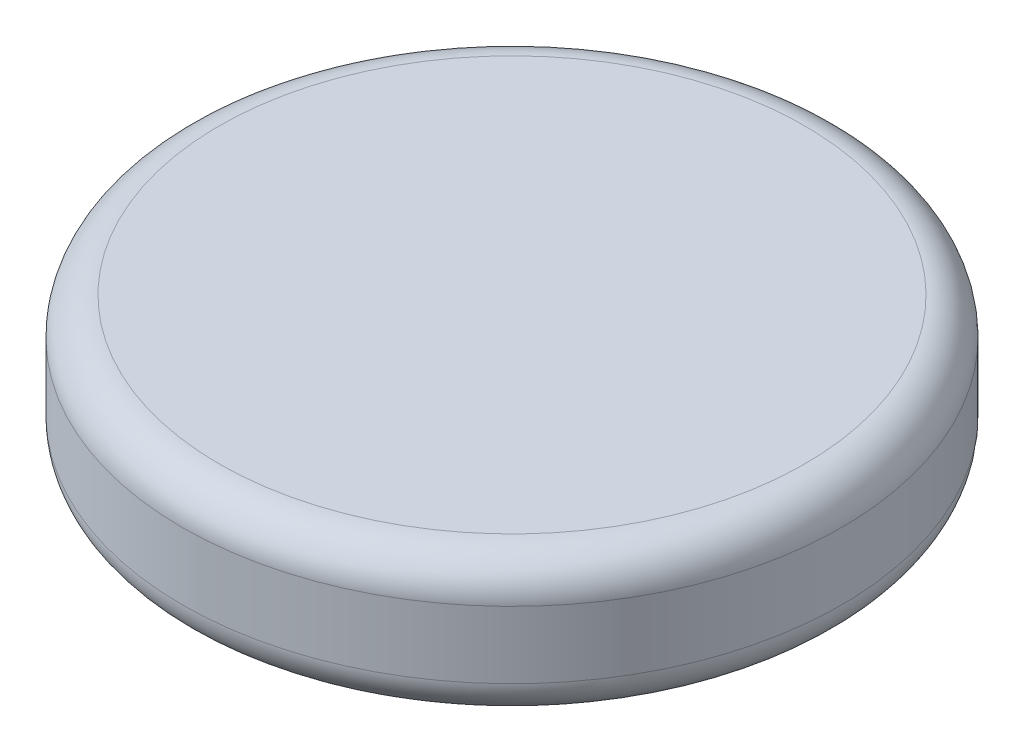
from build123d import *

# Parameters (mm, degrees)
SKETCH1_R           = 15.9385
BOSS_EXTRUDE1_DEPTH = 6.7945
FILLET1_R           = 1.778


with BuildPart() as part:
    # Sketch1 → Boss-Extrude1 (new body)
    with BuildSketch(Plane(origin=(0, 0, 0), x_dir=(1, 0, 0), z_dir=(0, 1, 0))):
        Circle(SKETCH1_R)
    extrude(amount=BOSS_EXTRUDE1_DEPTH)

    # Fillet1
    fillet1_edges = [part.edges().sort_by_distance(p)[0] for p in [
        (-15.9385, 0, 0),
        (-15.9385, 6.7945, 0),
    ]]
    fillet(fillet1_edges, radius=FILLET1_R)


solid = part.part
